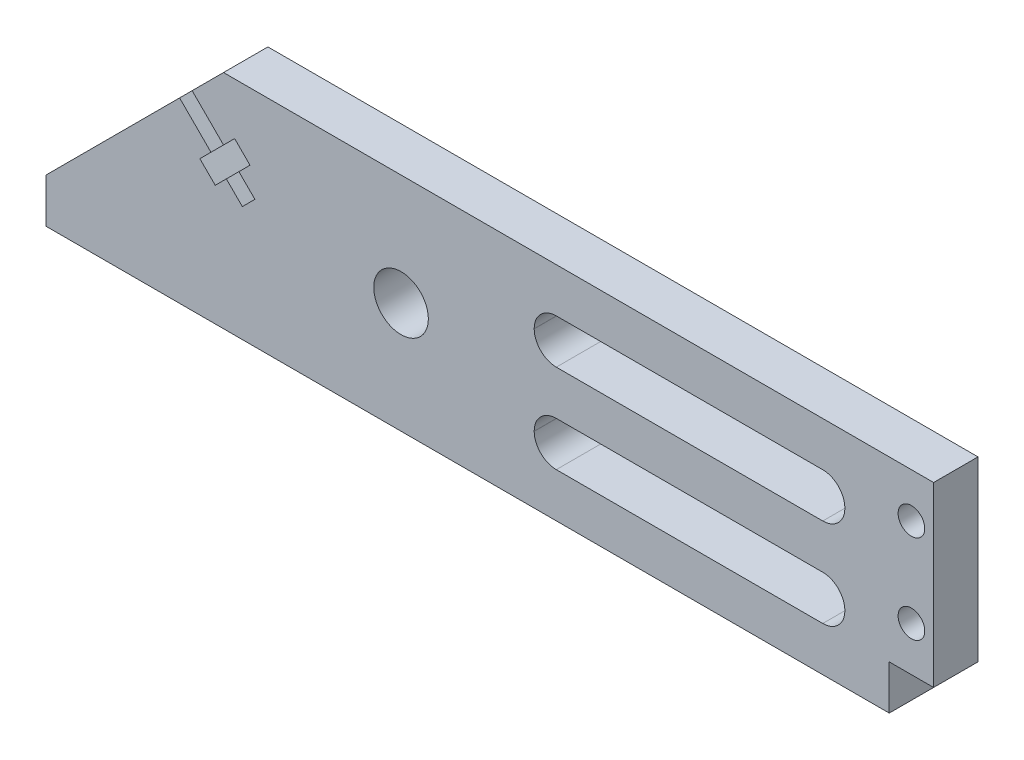
from build123d import *

# Parameters (mm, degrees)
RESSALTO_EXTRUS_O1_DEPTH = 5
ESBO_O2_W                = 95
ESBO_O2_H                = 5
RESSALTO_EXTRUS_O2_DEPTH = 5
ESBO_O5_W                = 5
ESBO_O5_H                = 2
CORTE_EXTRUS_O1_DEPTH    = 10
CORTE_EXTRUS_O2_DEPTH    = 10
ESBO_O8_R                = 3.075
CORTE_EXTRUS_O3_DEPTH    = 6
CORTE_EXTRUS_O4_DEPTH    = 10
ESBO_O10_R               = 1.5
CORTE_EXTRUS_O5_DEPTH    = 10


with BuildPart() as part:
    # Esboço1 → Ressalto-extrusão1 (new body)
    with BuildSketch(Plane.XY):
        Polygon((-44.712278576, -7.96460177), (-24.712278576, 12.03539823), (55.287721424, 12.03539823), (55.287721424, -7.96460177), align=None)
    extrude(amount=RESSALTO_EXTRUS_O1_DEPTH)

    # Esboço2 → Ressalto-extrusão2 (add)
    with BuildSketch(Plane.XZ.offset(7.96460177)):
        with Locations((2.787721424, 2.5)):
            Rectangle(ESBO_O2_W, ESBO_O2_H)
    extrude(amount=RESSALTO_EXTRUS_O2_DEPTH)

    # Esboço5 → Corte-extrusão1 (cut)
    with BuildSketch(Plane(origin=(-18.373838403, 18.373838403, 0), x_dir=(0, 0, 1), z_dir=(-0.707106781, 0.707106781, 0))):
        with Locations((2.5, -14.963908057)):
            Rectangle(ESBO_O5_W, ESBO_O5_H)
    extrude(amount=-CORTE_EXTRUS_O1_DEPTH, mode=Mode.SUBTRACT)

    # Esboço7 → Corte-extrusão2 (cut)
    with BuildSketch(Plane.XY.offset(5)):
        Polygon((-24.712278576, 4.964330418), (-23.460699574, 6.215909421), (-21.72828796, 4.483497807), (-22.979866962, 3.231918804), align=None)
        Polygon((-24.394080525, 1.817705242), (-25.645659528, 0.566126239), (-27.378071141, 2.298537853), (-26.126492139, 3.550116856), align=None)
    extrude(amount=-CORTE_EXTRUS_O2_DEPTH, mode=Mode.SUBTRACT)

    # Esboço8 → Corte-extrusão3 (cut, through all)
    with BuildSketch(Plane.XY.offset(5)):
        with Locations((-4.712278576, -0.46460177)):
            Circle(ESBO_O8_R)
    extrude(amount=-CORTE_EXTRUS_O3_DEPTH, mode=Mode.SUBTRACT)

    # Esboço9 → Corte-extrusão4 (cut)
    with BuildSketch(Plane.XY.offset(5)):
        with BuildLine():
            Line((12.777721424, 7.03539823), (42.797721424, 7.03539823))
            ThreePointArc((42.797721424, 7.03539823), (44.558417309, 6.306094115), (45.287721424, 4.54539823))
            Line((45.287721424, 4.54539823), (45.287721424, 4.52539823))
            ThreePointArc((45.287721424, 4.52539823), (44.558417309, 2.764702345), (42.797721424, 2.03539823))
            Line((42.797721424, 2.03539823), (12.777721424, 2.03539823))
            ThreePointArc((12.777721424, 2.03539823), (11.017025538, 2.764702345), (10.287721424, 4.52539823))
            Line((10.287721424, 4.52539823), (10.287721424, 4.54539823))
            ThreePointArc((10.287721424, 4.54539823), (11.017025538, 6.306094115), (12.777721424, 7.03539823))
        make_face()
        with BuildLine():
            Line((12.777721424, -2.96460177), (42.797721424, -2.96460177))
            ThreePointArc((42.797721424, -2.96460177), (44.558417309, -3.693905885), (45.287721424, -5.45460177))
            Line((45.287721424, -5.45460177), (45.287721424, -5.47460177))
            ThreePointArc((45.287721424, -5.47460177), (44.558417309, -7.235297655), (42.797721424, -7.96460177))
            Line((42.797721424, -7.96460177), (12.777721424, -7.96460177))
            ThreePointArc((12.777721424, -7.96460177), (11.017025538, -7.235297655), (10.287721424, -5.47460177))
            Line((10.287721424, -5.47460177), (10.287721424, -5.45460177))
            ThreePointArc((10.287721424, -5.45460177), (11.017025538, -3.693905885), (12.777721424, -2.96460177))
        make_face()
    extrude(amount=-CORTE_EXTRUS_O4_DEPTH, mode=Mode.SUBTRACT)

    # Esboço10 → Corte-extrusão5 (cut)
    with BuildSketch(Plane.XY.offset(5)):
        with Locations((52.787721424, 7.03539823)):
            Circle(ESBO_O10_R)
        with Locations((52.787721424, -2.96460177)):
            Circle(ESBO_O10_R)
    extrude(amount=-CORTE_EXTRUS_O5_DEPTH, mode=Mode.SUBTRACT)


solid = part.part
